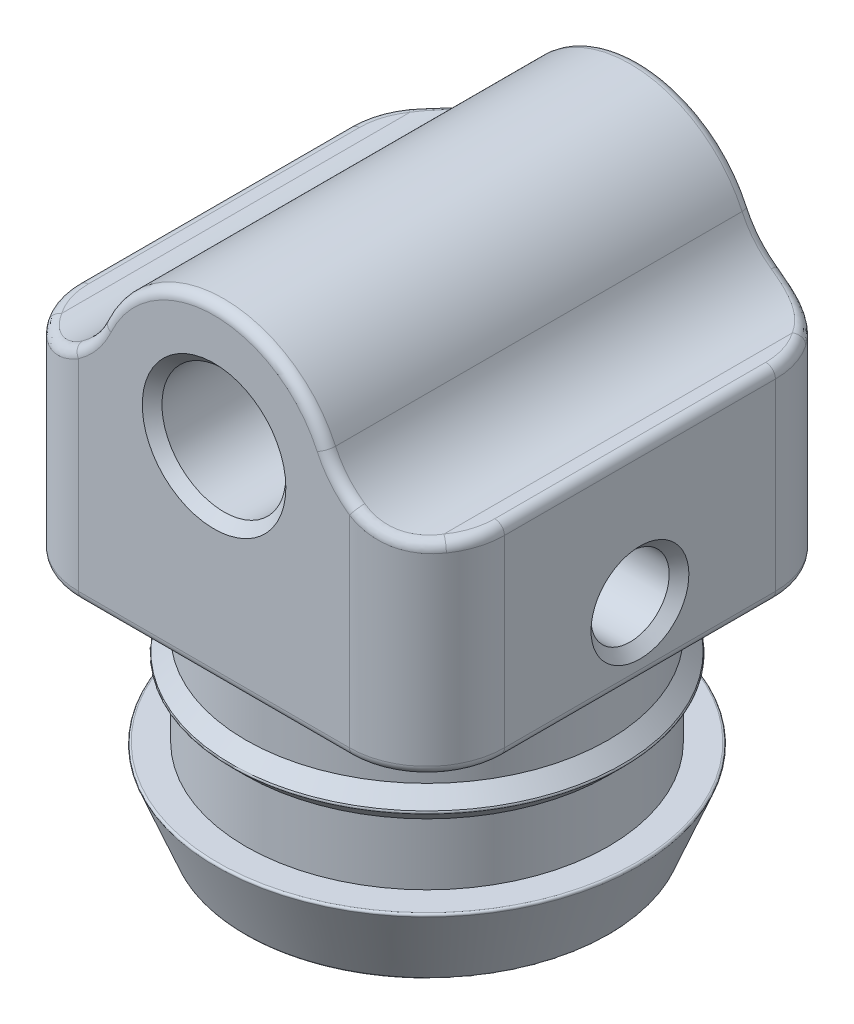
from build123d import *

# Parameters (mm, degrees)
SKETCH1_R                   = 3.2
BOSS_EXTRUDE1_DEPTH         = 11
SKETCH3_R                   = 2.38125
CUT_EXTRUDE1_DEPTH          = 18
F_10_32_TAPPED_HOLE1_REACH  = 35.471
F_10_32_TAPPED_HOLE1_BORE_R = 2.0193
FILLET3_R                   = 0.09921875
CHAMFER1_SIZE               = 0.508
FILLET7_R                   = 4.5
FILLET6_R                   = 4
FILLET8_R                   = 0.5


with BuildPart() as part:
    # Sketch1 → Boss-Extrude1 (new, symmetric)
    with BuildSketch(Plane.XY):
        with BuildLine():
            Line((-11, 0), (-6.35, 0))
            ThreePointArc((-6.35, 0), (0, 6.35), (6.35, 0))
            Line((6.35, 0), (11, 0))
            Line((11, 0), (11, -10.5))
            Line((11, -10.5), (-11, -10.5))
            Line((-11, -10.5), (-11, 0))
        make_face()
        Circle(SKETCH1_R, mode=Mode.SUBTRACT)
    extrude(amount=BOSS_EXTRUDE1_DEPTH, both=True)

    # Sketch2 → Revolve1 (revolve)
    with BuildSketch(Plane.XY, mode=Mode.PRIVATE) as revolve1_sk:
        Polygon((0, -10), (9.365, -10), (9.365, -13.96875), (10.15875, -14.7625), (9.365, -15.55625), (9.365, -18.73125), (10.9525, -18.73125), (9.365, -22.7), (0, -22.7), align=None)
    revolve(revolve1_sk.sketch.rotate(Axis((0, 9.54404991, 0), (0, -1, 0)), 180), axis=Axis((0, 9.54404991, 0), (0, -1, 0)))

    # Sketch3 → Cut-Extrude1 (cut)
    with BuildSketch(Plane.XZ.offset(22.7)):
        Circle(SKETCH3_R)
    extrude(amount=-CUT_EXTRUDE1_DEPTH, mode=Mode.SUBTRACT)

    # #10-32 Tapped Hole1 bore → #10-32 Tapped Hole1 (cut, up to next)
    with BuildSketch(Plane(origin=(11, 0, 0), x_dir=(0, 0, -1), z_dir=(1, 0, 0)), mode=Mode.PRIVATE) as f_10_32_tapped_hole1_sk1:
        with Locations((0, -7)):
            Circle(F_10_32_TAPPED_HOLE1_BORE_R)
    f_10_32_tapped_hole1_tool1 = extrude(f_10_32_tapped_hole1_sk1.sketch, amount=-F_10_32_TAPPED_HOLE1_REACH, mode=Mode.PRIVATE) & part.part
    add(f_10_32_tapped_hole1_tool1.solids().sort_by_distance((11, -7, 0))[0], mode=Mode.SUBTRACT)

    # Fillet3
    fillet3_edges = [part.edges().sort_by_distance(p)[0] for p in [
        (10.15875, -14.7625, 0),
        (10.9525, -18.73125, 0),
        (9.365, -22.7, 0),
        (-2.38125, -4.7, 0),
        (-2.38125, -22.7, 0),
        (1.892404965, -8.410112563, -1.445390956),
    ]]
    fillet(fillet3_edges, radius=FILLET3_R)

    # Chamfer1
    chamfer1_edges = [part.edges().sort_by_distance(p)[0] for p in [
        (-3.2, 0, -11),
        (-3.2, 0, 11),
        (11, -7, 2.0193),
    ]]
    chamfer(chamfer1_edges, length=CHAMFER1_SIZE)

    # Fillet7
    fillet7_edges = [part.edges().sort_by_distance(p)[0] for p in [
        (6.35, 0, 0),
        (-6.35, 0, 0),
    ]]
    fillet(fillet7_edges, radius=FILLET7_R)

    # Fillet6
    fillet6_edges = [part.edges().sort_by_distance(p)[0] for p in [
        (11, -5.25, -11),
        (-11, -5.25, -11),
        (-11, -5.25, 11),
        (11, -5.25, 11),
    ]]
    fillet(fillet6_edges, radius=FILLET6_R)

    # Fillet8
    fillet8_edges = [part.edges().sort_by_distance(p)[0] for p in [
        (0, 6.35, -11),
        (0, 6.35, 11),
        (-6.298677383, 1.765858158, 11),
        (6.298677383, 1.765858158, -11),
        (11, 0, 0),
        (11, -10.5, 0),
        (10.707510274, 0, 8.501455151),
        (10.707510274, 0, -8.501455151),
        (6.298677383, 1.765858158, 11),
        (8.469550334, 0.224389567, 10.720271757),
        (8.469550334, 0.224389567, -10.720271757),
        (0, -10.5, -11),
        (-6.298677383, 1.765858158, -11),
        (0, -10.5, 11),
        (-11, -10.5, 0),
        (9.828427125, -10.5, 9.828427125),
        (-9.828427125, -10.5, 9.828427125),
        (-9.828427125, -10.5, -9.828427125),
        (9.828427125, -10.5, -9.828427125),
        (-11, 0, 0),
        (-8.469550334, 0.224389567, 10.720271757),
        (-8.469550334, 0.224389567, -10.720271757),
        (-10.707510274, 0, 8.501455151),
        (-10.707510274, 0, -8.501455151),
    ]]
    fillet(fillet8_edges, radius=FILLET8_R)


solid = part.part
